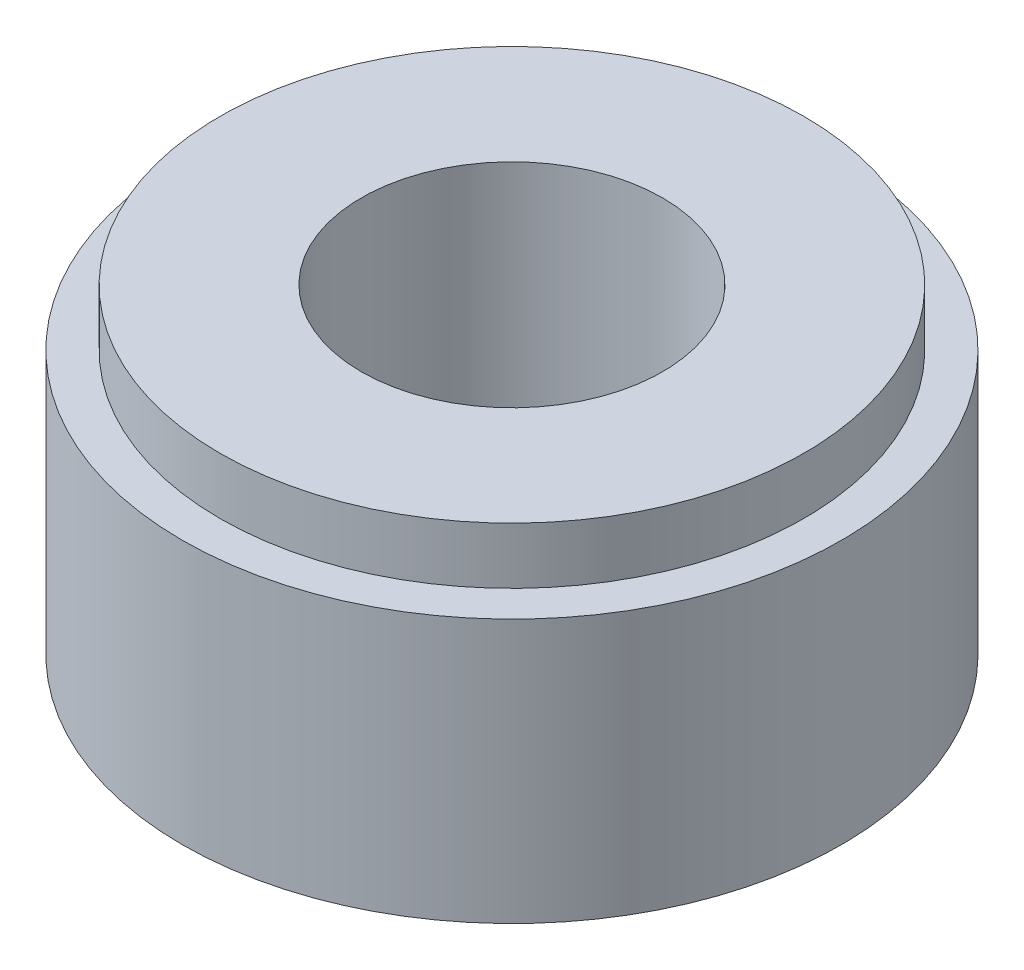
from build123d import *

# Parameters (mm, degrees)
SKETCH1_R           = 17.5
BOSS_EXTRUDE1_DEPTH = 14
SKETCH2_R           = 15.5
BOSS_EXTRUDE2_DEPTH = 3
SKETCH3_R           = 8
CUT_EXTRUDE1_DEPTH  = 18


with BuildPart() as part:
    # Sketch1 → Boss-Extrude1 (new body)
    with BuildSketch(Plane(origin=(0, 0, 0), x_dir=(1, 0, 0), z_dir=(0, 1, 0))):
        Circle(SKETCH1_R)
    extrude(amount=BOSS_EXTRUDE1_DEPTH)

    # Sketch2 → Boss-Extrude2 (add)
    with BuildSketch(Plane(origin=(0, 14, 0), x_dir=(1, 0, 0), z_dir=(0, 1, 0))):
        Circle(SKETCH2_R)
    extrude(amount=BOSS_EXTRUDE2_DEPTH)

    # Sketch3 → Cut-Extrude1 (cut, through all)
    with BuildSketch(Plane(origin=(0, 17, 0), x_dir=(1, 0, 0), z_dir=(0, 1, 0))):
        Circle(SKETCH3_R)
    extrude(amount=-CUT_EXTRUDE1_DEPTH, mode=Mode.SUBTRACT)


solid = part.part
